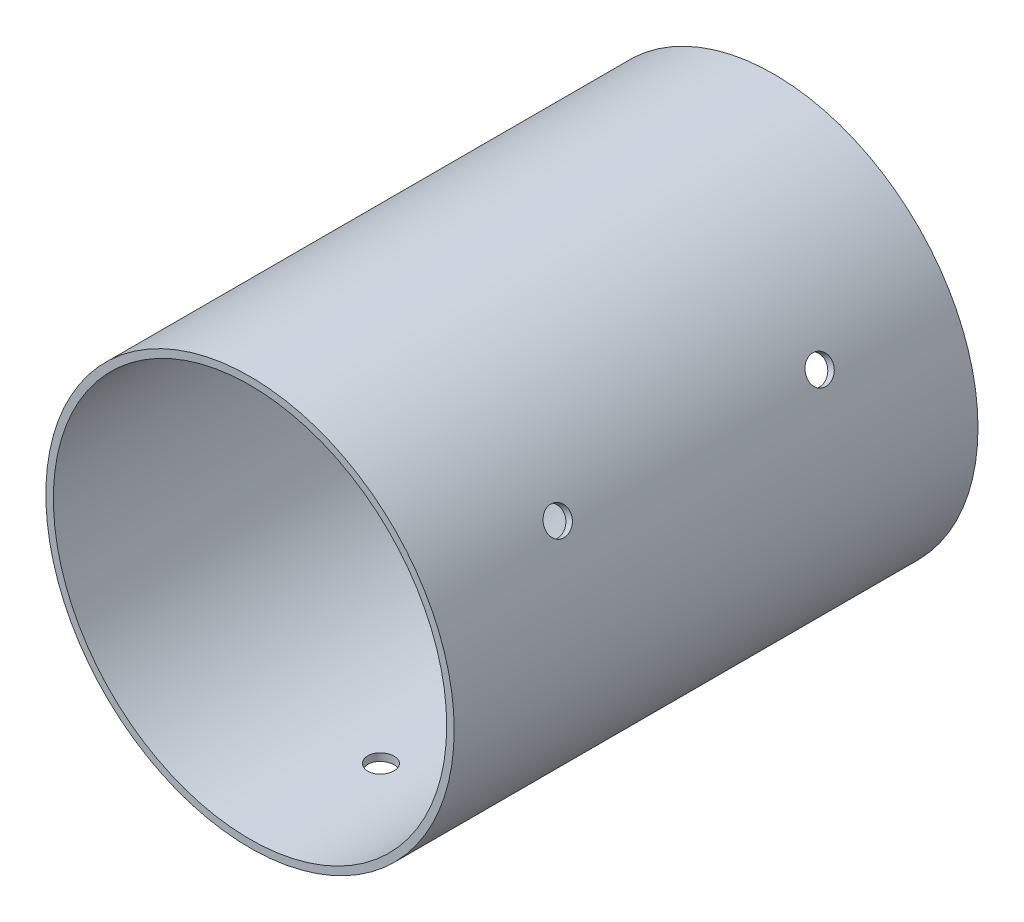
from build123d import *

# Parameters (mm, degrees)
SKETCH1_R           = 49.5046
SKETCH1_R_2         = 47.6885
BOSS_EXTRUDE1_DEPTH = 127
SKETCH4_R           = 3.175
CUT_EXTRUDE3_DEPTH  = 146.018656877
CIRPATTERN2_COUNT   = 3


with BuildPart() as part:
    # Sketch1 → Boss-Extrude1 (new body)
    with BuildSketch(Plane.XY):
        Circle(SKETCH1_R)
        Circle(SKETCH1_R_2, mode=Mode.SUBTRACT)
    extrude(amount=BOSS_EXTRUDE1_DEPTH)

    # Sketch4 → Cut-Extrude3 (cut, through all)
    with BuildSketch(Plane(origin=(0, 0, 0), x_dir=(1, 0, 0), z_dir=(0, 1, 0))):
        with Locations((0, -31.75)):
            Circle(SKETCH4_R)
        with Locations((0, -95.25)):
            Circle(SKETCH4_R)
    cut_extrude3 = extrude(amount=-CUT_EXTRUDE3_DEPTH, mode=Mode.SUBTRACT)

    # CirPattern2: Cut-Extrude3 ×3 about axis
    cirpattern2_axis = Axis((0, 0, 127), (0, 0, -1))
    for i in range(1, CIRPATTERN2_COUNT):
        add(cut_extrude3.rotate(cirpattern2_axis, i * 360 / CIRPATTERN2_COUNT), mode=Mode.SUBTRACT)


solid = part.part
